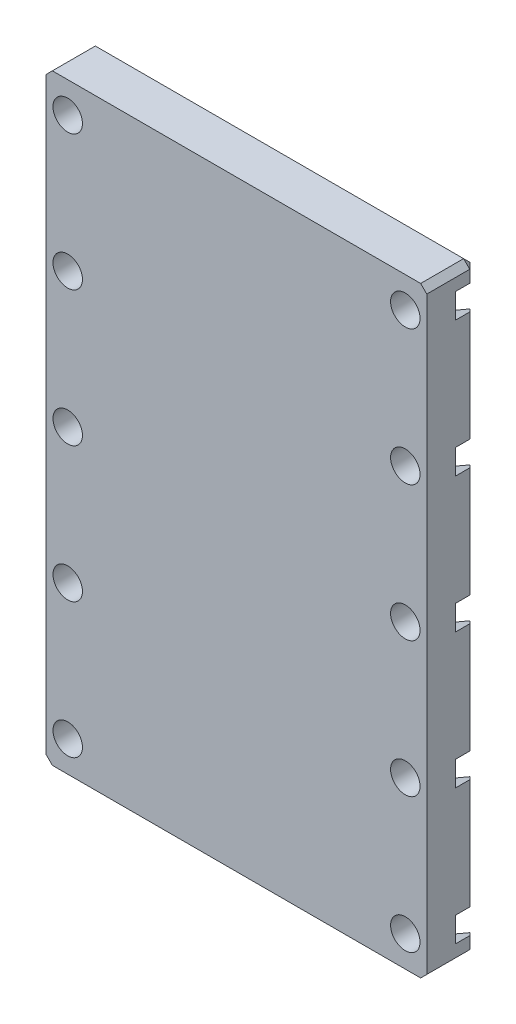
from build123d import *

# Parameters (mm, degrees)
SKETCH_1_W            = 62
SKETCH_1_H            = 98
EXTRUDE_1_DEPTH       = 8
CHAMFER_1_SIZE        = 1
HOLE_WIZARD_M4_1_D    = 4.8
CUT_EXTRUDE_1_DEPTH   = 3.3
MIRROR_2_COPY_1_D     = 4.8
MIRROR_2_COPY_2_DEPTH = 3.3


with BuildPart() as part:
    # ｽｹｯﾁ1 → ﾎﾞｽ - 押し出し1 (new body)
    with BuildSketch(Plane.XY):
        Rectangle(SKETCH_1_W, SKETCH_1_H)
    extrude(amount=EXTRUDE_1_DEPTH)

    # 面取り1
    chamfer_1_edges = [part.edges().sort_by_distance(p)[0] for p in [
        (0, -49, 0),
        (-31, 0, 0),
        (0, 49, 0),
        (31, 0, 0),
        (31, -49, 4),
        (-31, -49, 4),
        (-31, 49, 4),
        (31, 49, 4),
    ]]
    chamfer(chamfer_1_edges, length=CHAMFER_1_SIZE)

    # M4 すきま穴1 (through all)
    with Locations(Plane.XY.offset(8)):
        with Locations((-27.5, 44), (-27.5, 22), (-27.5, 0)):
            hole_wizard_m4_1 = Hole(HOLE_WIZARD_M4_1_D / 2)

    # ｽｹｯﾁ6 → ｶｯﾄ - 押し出し1 (cut)
    with BuildSketch(Plane(origin=(0, 0, 0), x_dir=(-1, 0, 0), z_dir=(0, 0, -1))):
        Polygon((27.5, 17.958548116), (31, 19.979274058), (31, 24.020725942), (27.5, 26.041451884), (24, 24.020725942), (24, 19.979274058), align=None)
        Polygon((27.5, 39.958548116), (31, 41.979274058), (31, 46.020725942), (27.5, 48.041451884), (24, 46.020725942), (24, 41.979274058), align=None)
        Polygon((27.5, -4.041451884), (31, -2.020725942), (31, 2.020725942), (27.5, 4.041451884), (24, 2.020725942), (24, -2.020725942), align=None)
    cut_extrude_1 = extrude(amount=-CUT_EXTRUDE_1_DEPTH, mode=Mode.SUBTRACT)

    # ﾐﾗｰ1: M4 すきま穴1, ｶｯﾄ - 押し出し1 across plane
    add(hole_wizard_m4_1.mirror(Plane.ZX), mode=Mode.SUBTRACT)
    add(cut_extrude_1.mirror(Plane.ZX), mode=Mode.SUBTRACT)

    # ﾐﾗｰ2: M4 すきま穴1, ｶｯﾄ - 押し出し1 across plane
    add(hole_wizard_m4_1.mirror(Plane(origin=(0, 0, 0), x_dir=(0, 0, 1), z_dir=(1, 0, 0))), mode=Mode.SUBTRACT)
    add(cut_extrude_1.mirror(Plane(origin=(0, 0, 0), x_dir=(0, 0, 1), z_dir=(1, 0, 0))), mode=Mode.SUBTRACT)

    # ﾐﾗｰ2 copy 1 (through all)
    with Locations(Plane(origin=(0, 0, 8), x_dir=(-1, 0, 0), z_dir=(0, 0, 1))):
        with Locations((-27.5, 44), (-27.5, 22), (-27.5, 0)):
            Hole(MIRROR_2_COPY_1_D / 2)

    # ﾐﾗｰ2 copy 2 sketch → ﾐﾗｰ2 copy 2 (cut)
    with BuildSketch(Plane(origin=(0, 0, 0), x_dir=(1, 0, 0), z_dir=(0, 0, -1))):
        Polygon((27.5, 17.958548116), (31, 19.979274058), (31, 24.020725942), (27.5, 26.041451884), (24, 24.020725942), (24, 19.979274058), align=None)
        Polygon((27.5, 39.958548116), (31, 41.979274058), (31, 46.020725942), (27.5, 48.041451884), (24, 46.020725942), (24, 41.979274058), align=None)
        Polygon((27.5, -4.041451884), (31, -2.020725942), (31, 2.020725942), (27.5, 4.041451884), (24, 2.020725942), (24, -2.020725942), align=None)
    extrude(amount=-MIRROR_2_COPY_2_DEPTH, mode=Mode.SUBTRACT)


solid = part.part
